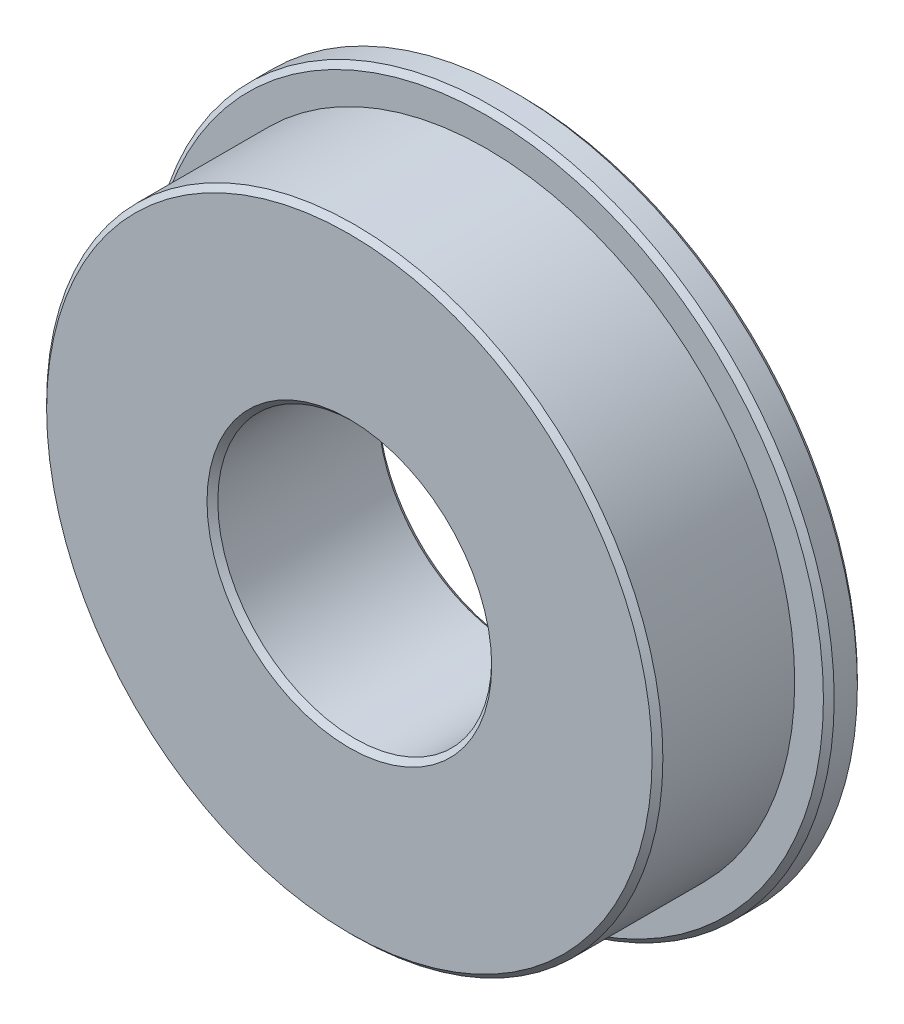
from build123d import *

# Parameters (mm, degrees)
CHAMFER1_SIZE = 0.25


with BuildPart() as part:
    # Sketch1 → Revolve1 (revolve)
    with BuildSketch(Plane(origin=(0, 0, 0), x_dir=(1, 0, 0), z_dir=(0, 1, 0))):
        Polygon((-14.287497289, 6.362699291), (-14.287497289, 0), (-6.349997937, 0), (-6.349997937, 7.937499291), (-15.868754486, 7.937499291), (-15.868754486, 6.362699291), align=None)
    revolve(axis=Axis((0, 0, 0), (0, 0, -1)))

    # Chamfer1
    chamfer1_edges = [part.edges().sort_by_distance(p)[0] for p in [
        (14.287497289, 0, 0),
        (6.349997937, 0, 0),
        (6.349997937, 0, -7.937499291),
        (15.868754486, 0, -7.937499291),
        (15.868754486, 0, -6.362699291),
    ]]
    chamfer(chamfer1_edges, length=CHAMFER1_SIZE)


solid = part.part
